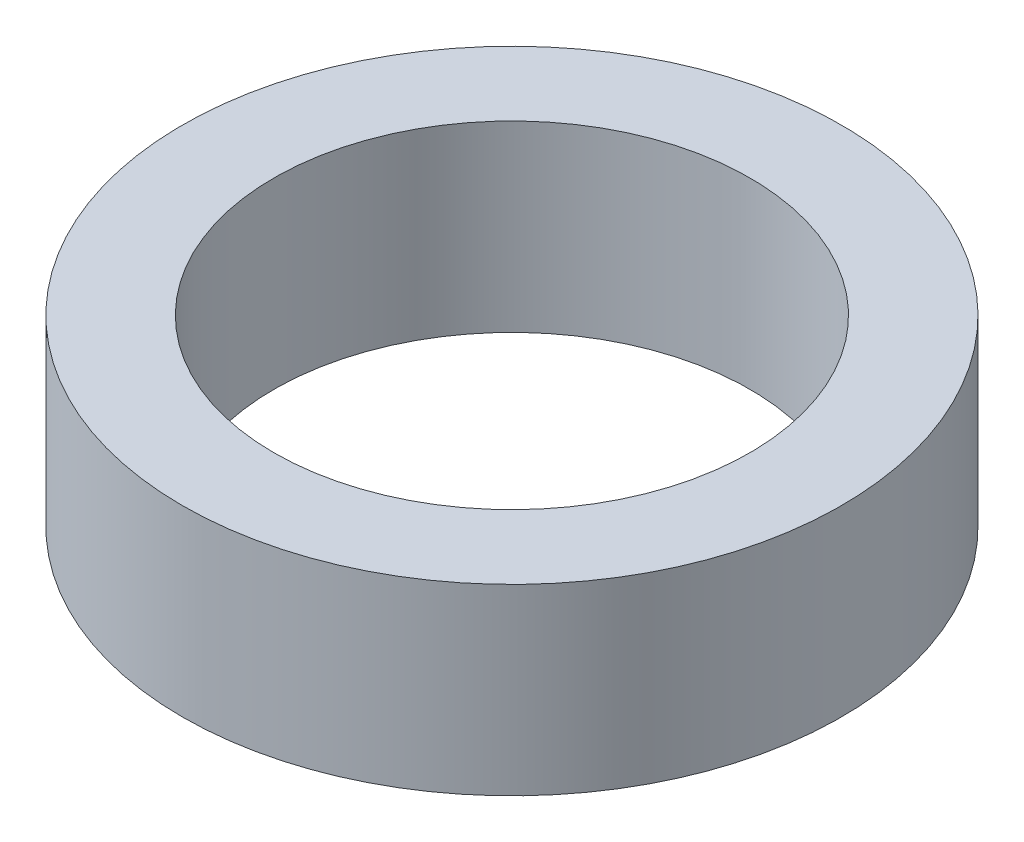
from build123d import *

# Parameters (mm, degrees)
SKETCH1_W = 5
SKETCH1_H = 10


with BuildPart() as part:
    # Sketch1 → Revolve1 (revolve)
    with BuildSketch(Plane.XY):
        with Locations((15.5, 1.277290873)):
            Rectangle(SKETCH1_W, SKETCH1_H)
    revolve(axis=Axis((0, 11.223214286, 0), (0, -1, 0)))


solid = part.part
